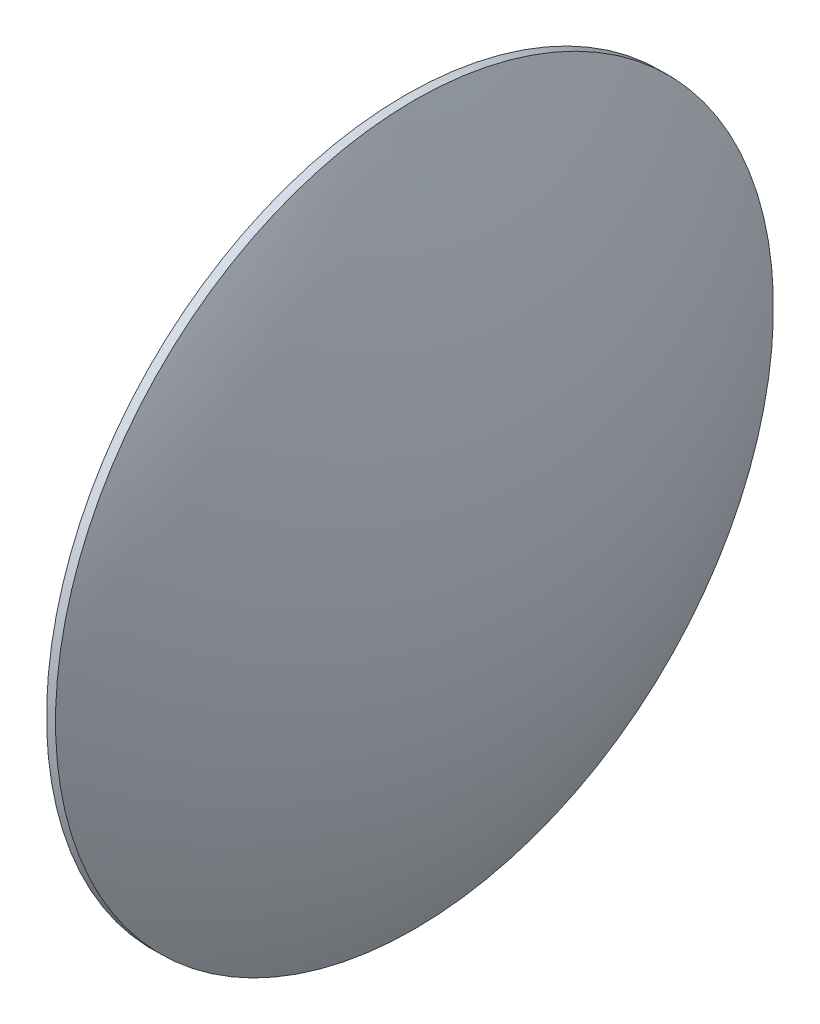
from build123d import *


with BuildPart() as part:
    # Esboço1 → Revolução1 (revolve)
    with BuildSketch(Plane.XY):
        with BuildLine():
            Line((26.516236901, 0), (34.202561511, 0))
            ThreePointArc((34.202561511, 0), (33.278042199, 7.991346311), (30.553326319, 15.560512394))
            Line((30.553326319, 15.560512394), (30.165472093, 15.560512394))
            ThreePointArc((30.165472093, 15.560512394), (27.440756213, 7.991346311), (26.516236901, 0))
        make_face()
    revolve(axis=Axis((26.516236901, 0, 0), (1, 0, 0)))


solid = part.part
